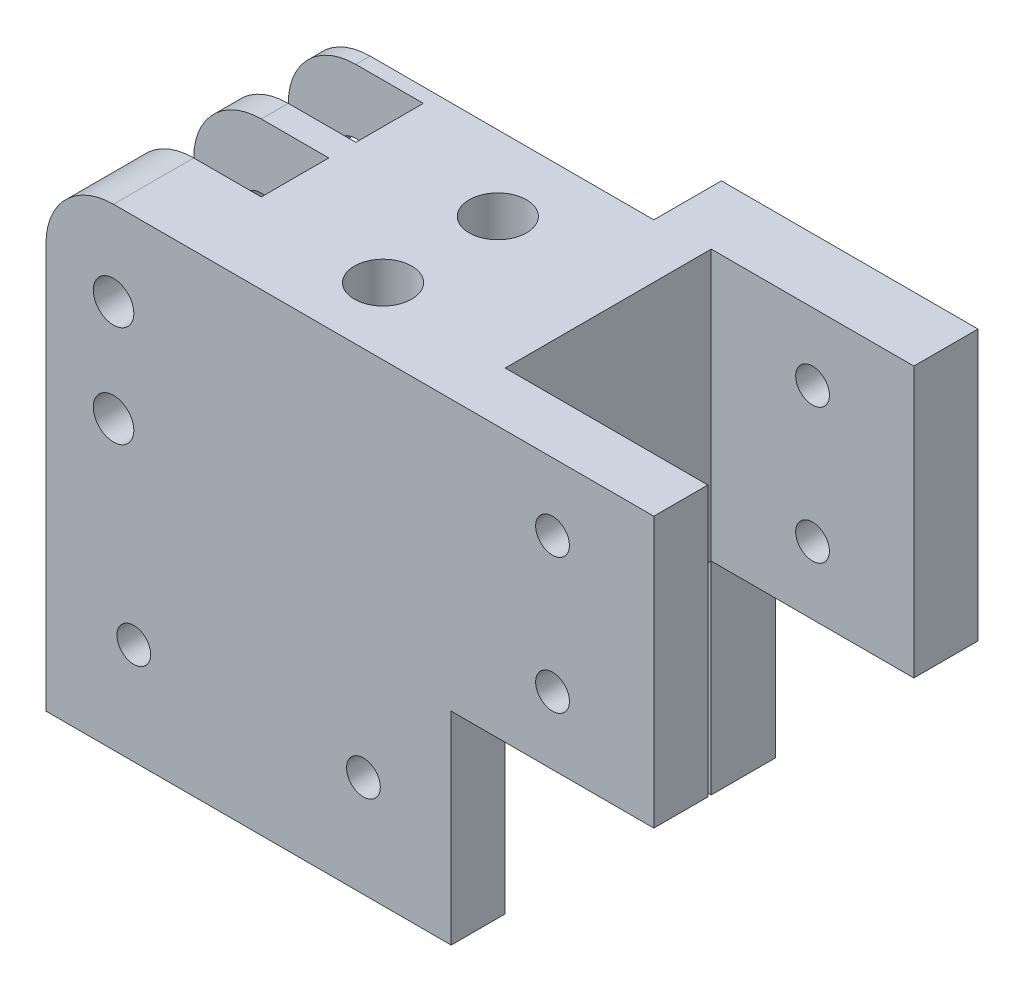
from build123d import *

# Parameters (mm, degrees)
RESSALTO_EXTRUS_O1_DEPTH                   = 8
BROCA_DE_ROSQUEAR_PARA_TARRAXA_DE_M6X1_0_D = 5
RESSALTO_EXTRUS_O2_DEPTH                   = 30
ESBO_O6_W                                  = 10
ESBO_O6_H                                  = 40
ESBO_O6_H_2                                = 25
CORTE_EXTRUS_O2_DEPTH                      = 20
ESBO_O14_R                                 = 3
CORTE_EXTRUS_O6_DEPTH                      = 39
ESBO_O15_R                                 = 4.25
CORTE_EXTRUS_O7_DEPTH                      = 40
RESSALTO_EXTRUS_O3_DEPTH                   = 10
ESBO_O17_W                                 = 60
ESBO_O17_H                                 = 9.5
RESSALTO_EXTRUS_O4_DEPTH                   = 30
ESBO_O18_W                                 = 9.5
ESBO_O18_H                                 = 40
RESSALTO_EXTRUS_O5_DEPTH                   = 30
FILETE1_R                                  = 5
ESBO_O19_R                                 = 2.5
CORTE_EXTRUS_O8_DEPTH                      = 10
ESBO_O20_R                                 = 2.5
CORTE_EXTRUS_O9_DEPTH                      = 10


with BuildPart() as part:
    # Esboço1 → Ressalto-extrusão1 (new body)
    with BuildSketch(Plane.XY):
        with BuildLine():
            Line((440, 72.212171493), (380, 72.212171493))
            Line((380, 72.212171493), (380, 132.212171493))
            ThreePointArc((380, 132.212171493), (382.928932188, 139.283239304), (390, 142.212171493))
            Line((390, 142.212171493), (470, 142.212171493))
            Line((470, 142.212171493), (470, 102.212171493))
            Line((470, 102.212171493), (440, 102.212171493))
            Line((440, 102.212171493), (440, 72.212171493))
        make_face()
    extrude(amount=RESSALTO_EXTRUS_O1_DEPTH)

    # Broca de rosquear para tarraxa de M6x1.01 (through all)
    with Locations(Plane.XY.offset(8)):
        with Locations((393, 87.212171493), (427, 87.212171493), (455, 112.212171493), (455, 132.212171493)):
            Hole(BROCA_DE_ROSQUEAR_PARA_TARRAXA_DE_M6X1_0_D / 2)

    # Esboço4 → Ressalto-extrusão2 (add)
    with BuildSketch(Plane(origin=(0, 0, 0), x_dir=(-1, 0, 0), z_dir=(0, 0, -1))):
        with BuildLine():
            Line((-390, 142.212171493), (-440, 142.212171493))
            Line((-440, 142.212171493), (-440, 102.212171493))
            Line((-440, 102.212171493), (-380, 102.212171493))
            Line((-380, 102.212171493), (-380, 132.212171493))
            ThreePointArc((-380, 132.212171493), (-382.928932188, 139.283239304), (-390, 142.212171493))
        make_face()
    extrude(amount=RESSALTO_EXTRUS_O2_DEPTH)

    # Esboço6 → Corte-extrusão2 (cut)
    with BuildSketch(Plane.ZY.offset(-380)):
        with Locations((-22.874860756, 122.212171493)):
            Rectangle(ESBO_O6_W, ESBO_O6_H)
        with Locations((-8.874860756, 129.712171493)):
            Rectangle(ESBO_O6_W, ESBO_O6_H_2)
    extrude(amount=-CORTE_EXTRUS_O2_DEPTH, mode=Mode.SUBTRACT)

    # Esboço14 → Corte-extrusão6 (cut, through all)
    with BuildSketch(Plane(origin=(0, 0, -30), x_dir=(-1, 0, 0), z_dir=(0, 0, -1))):
        with Locations((-390, 129.712171493)):
            Circle(ESBO_O14_R)
        with Locations((-390, 114.712171493)):
            Circle(ESBO_O14_R)
    extrude(amount=-CORTE_EXTRUS_O6_DEPTH, mode=Mode.SUBTRACT)

    # Esboço15 → Corte-extrusão7 (cut)
    with BuildSketch(Plane(origin=(0, 142.212171493, 0), x_dir=(1, 0, 0), z_dir=(0, 1, 0))):
        with Locations((420, 18.90241208)):
            Circle(ESBO_O15_R)
        with Locations((420, 1.90241208)):
            Circle(ESBO_O15_R)
    extrude(amount=-CORTE_EXTRUS_O7_DEPTH, mode=Mode.SUBTRACT)

    # Esboço16 → Ressalto-extrusão3 (add)
    with BuildSketch(Plane(origin=(0, 0, -30), x_dir=(-1, 0, 0), z_dir=(0, 0, -1))):
        with BuildLine():
            Line((-380, 102.212171493), (-440, 102.212171493))
            Line((-440, 102.212171493), (-440, 110.212171493))
            Line((-440, 110.212171493), (-440, 142.212171493))
            Line((-440, 142.212171493), (-432, 142.212171493))
            Line((-432, 142.212171493), (-432, 110.212171493))
            Line((-432, 110.212171493), (-394.815024021, 110.212171493))
            ThreePointArc((-394.815024021, 110.212171493), (-391.180367629, 108.706647521), (-387.545711238, 110.212171493))
            Line((-387.545711238, 110.212171493), (-380, 110.212171493))
            Line((-380, 110.212171493), (-380, 102.212171493))
        make_face()
    extrude(amount=RESSALTO_EXTRUS_O3_DEPTH)

    # Esboço17 → Ressalto-extrusão4 (add, through all)
    with BuildSketch(Plane.XZ.offset(-102.212171493)):
        with Locations((410, -35.25)):
            Rectangle(ESBO_O17_W, ESBO_O17_H)
    extrude(amount=RESSALTO_EXTRUS_O4_DEPTH)

    # Esboço18 → Ressalto-extrusão5 (add, through all)
    with BuildSketch(Plane(origin=(440, 0, 0), x_dir=(0, 0, -1), z_dir=(1, 0, 0))):
        with Locations((35.25, 122.212171493)):
            Rectangle(ESBO_O18_W, ESBO_O18_H)
    extrude(amount=RESSALTO_EXTRUS_O5_DEPTH)

    # Filete1
    filete1_edges = [part.edges().sort_by_distance(p)[0] for p in [
        (432, 110.212171493, -35),
    ]]
    fillet(filete1_edges, radius=FILETE1_R)

    # Esboço19 → Corte-extrusão8 (cut)
    with BuildSketch(Plane.XY.offset(-30.5)):
        with Locations((455, 132.212171493)):
            Circle(ESBO_O19_R)
        with Locations((455, 112.212171493)):
            Circle(ESBO_O19_R)
    extrude(amount=-CORTE_EXTRUS_O8_DEPTH, mode=Mode.SUBTRACT)

    # Esboço20 → Corte-extrusão9 (cut)
    with BuildSketch(Plane.XY.offset(-30.5)):
        with Locations((427, 87.212171493)):
            Circle(ESBO_O20_R)
        with Locations((393, 87.212171493)):
            Circle(ESBO_O20_R)
    extrude(amount=-CORTE_EXTRUS_O9_DEPTH, mode=Mode.SUBTRACT)


solid = part.part
